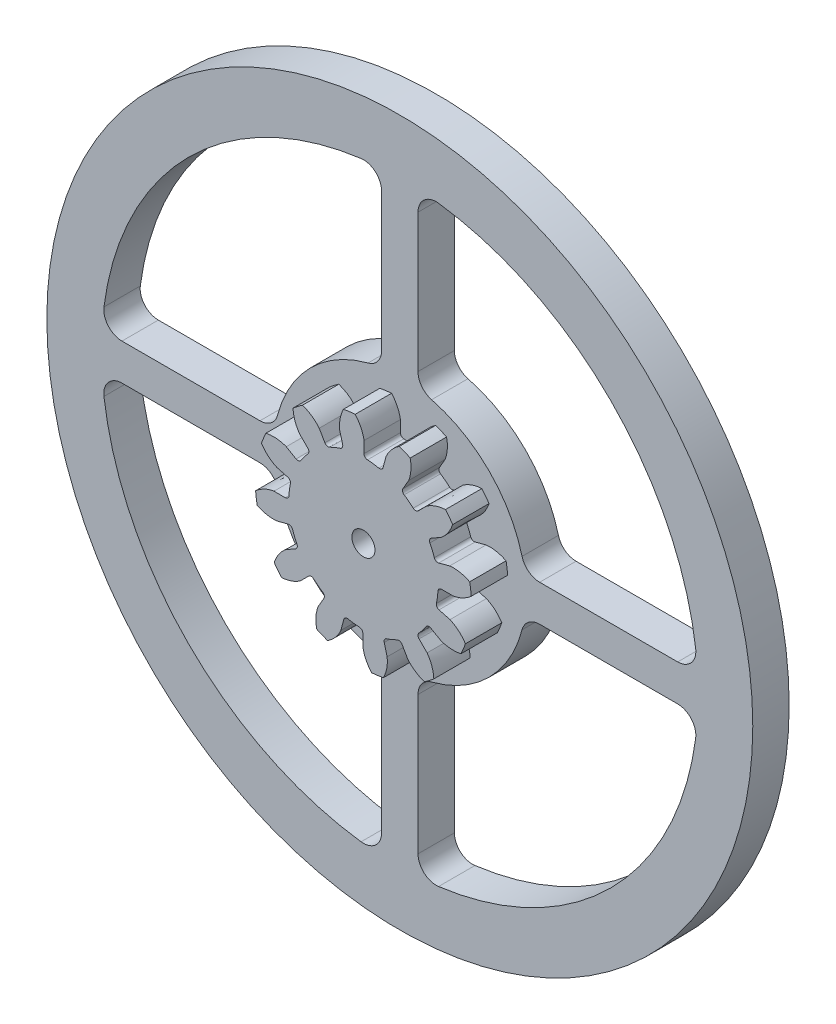
from build123d import *

# Parameters (mm, degrees)
SKETCH1_R                = 14.859
BOSS_EXTRUDE1_DEPTH      = 5
CUT_EXTRUDE1_DEPTH       = 22.600457449
FILLET1_R                = 0.498729
CIRPATTERN1_COUNT        = 12
FILLET1_OF_CIRPATTERN1_R = 0.498729
SKETCH5_R                = 1.5875
CUT_EXTRUDE2_DEPTH       = 22.541370702
SKETCH6_R                = 48.510317
SKETCH6_R_2              = 1.5875
BOSS_EXTRUDE2_DEPTH      = 5
CUT_EXTRUDE3_DEPTH       = 69.785912302


with BuildPart() as part:
    # Sketch1 → Boss-Extrude1 (new body)
    with BuildSketch(Plane.XY):
        Circle(SKETCH1_R)
    extrude(amount=-BOSS_EXTRUDE1_DEPTH)

    # Sketch4 → Cut-Extrude1 (cut, through all)
    with BuildSketch(Plane.XY):
        with BuildLine():
            Line((0.080131787, 12.295213914), (0.080131787, 10.250703468))
            ThreePointArc((0.080131787, 10.250703468), (1.338029283, 10.163317388), (2.575681995, 9.922157274))
            Line((2.575681995, 9.922157274), (3.104841445, 11.897002391))
            add(Edge.make_bspline(
                [(5.071151281, 14.112882844), (3.70540161, 13.261726884), (3.104841445, 11.897002391)],
                knots=[0, 0, 0, 1, 1, 1], degree=2))
            ThreePointArc((5.071151281, 14.112882844), (1.957418943, 14.868037818), (-1.245663981, 14.944509317))
            add(Edge.make_bspline(
                [(-1.245663981, 14.944509317), (-0.146747194, 13.768873094), (0.080131787, 12.295213914)],
                knots=[0, 0, 0, 1, 1, 1], degree=2))
        make_face()
    cut_extrude1 = extrude(amount=-CUT_EXTRUDE1_DEPTH, mode=Mode.SUBTRACT)

    # Fillet1
    fillet1_edges = [part.edges().sort_by_distance(p)[0] for p in [
        (2.575681995, 9.922157274, -2.5),
        (0.080131787, 10.250703468, -2.5),
    ]]
    fillet(fillet1_edges, radius=FILLET1_R)

    # CirPattern1: Cut-Extrude1 ×12 about axis
    cirpattern1_axis = Axis((0, 0, -5), (0, 0, 1))
    for i in range(1, CIRPATTERN1_COUNT):
        add(cut_extrude1.rotate(cirpattern1_axis, i * 360 / CIRPATTERN1_COUNT), mode=Mode.SUBTRACT)

    # Fillet1 of CirPattern1
    fillet1_of_cirpattern1_edges = [part.edges().sort_by_distance(p)[0] for p in [
        (-2.730472597, 9.880681257, -2.5),
        (-5.055955571, 8.917435504, -2.5),
        (-7.304999262, 7.191684677, -2.5),
        (-8.837303717, 5.194747897, -2.5),
        (-9.922157274, 2.575681995, -2.5),
        (-10.250703468, 0.080131787, -2.5),
        (-9.880681257, -2.730472597, -2.5),
        (-8.917435504, -5.055955571, -2.5),
        (-7.191684677, -7.304999262, -2.5),
        (-5.194747897, -8.837303717, -2.5),
        (-2.575681995, -9.922157274, -2.5),
        (-0.080131787, -10.250703468, -2.5),
        (2.730472597, -9.880681257, -2.5),
        (5.055955571, -8.917435504, -2.5),
        (7.304999262, -7.191684677, -2.5),
        (8.837303717, -5.194747897, -2.5),
        (9.922157274, -2.575681995, -2.5),
        (10.250703468, -0.080131787, -2.5),
        (9.880681257, 2.730472597, -2.5),
        (8.917435504, 5.055955571, -2.5),
        (7.191684677, 7.304999262, -2.5),
        (5.194747897, 8.837303717, -2.5),
    ]]
    fillet(fillet1_of_cirpattern1_edges, radius=FILLET1_OF_CIRPATTERN1_R)

    # Sketch5 → Cut-Extrude2 (cut, through all)
    with BuildSketch(Plane.XY):
        Circle(SKETCH5_R)
    extrude(amount=-CUT_EXTRUDE2_DEPTH, mode=Mode.SUBTRACT)

    # Sketch6 → Boss-Extrude2 (add)
    with BuildSketch(Plane(origin=(0, 0, -5), x_dir=(-1, 0, 0), z_dir=(0, 0, -1))):
        Circle(SKETCH6_R)
        with Locations(Location((0, 0, 0), (0, 0, 180))):
            Circle(SKETCH6_R_2, mode=Mode.SUBTRACT)
    extrude(amount=BOSS_EXTRUDE2_DEPTH)

    # Sketch7 → Cut-Extrude3 (cut, through all)
    with BuildSketch(Plane.XY.offset(-5)):
        with BuildLine():
            Line((2.5, 19.219258076), (2.5, 38.18434909))
            ThreePointArc((2.5, 38.18434909), (3.350980725, 40.063374218), (5.324588343, 40.663188013))
            ThreePointArc((5.324588343, 40.663188013), (28.998673249, 28.998673249), (40.663188013, 5.324588343))
            ThreePointArc((40.663188013, 5.324588343), (40.063374218, 3.350980725), (38.18434909, 2.5))
            Line((38.18434909, 2.5), (19.219258076, 2.5))
            ThreePointArc((19.219258076, 2.5), (17.690139676, 3.022173689), (16.799793592, 4.370562465))
            ThreePointArc((16.799793592, 4.370562465), (12.274666615, 12.274666615), (4.370562465, 16.799793592))
            ThreePointArc((4.370562465, 16.799793592), (3.022173689, 17.690139676), (2.5, 19.219258076))
        make_face()
        with BuildLine():
            Line((19.219258076, -2.5), (38.18434909, -2.5))
            ThreePointArc((38.18434909, -2.5), (40.063374218, -3.350980725), (40.663188013, -5.324588343))
            ThreePointArc((40.663188013, -5.324588343), (28.998673249, -28.998673249), (5.324588343, -40.663188013))
            ThreePointArc((5.324588343, -40.663188013), (3.350980725, -40.063374218), (2.5, -38.18434909))
            Line((2.5, -38.18434909), (2.5, -19.219258076))
            ThreePointArc((2.5, -19.219258076), (3.022173689, -17.690139676), (4.370562465, -16.799793592))
            ThreePointArc((4.370562465, -16.799793592), (12.274666615, -12.274666615), (16.799793592, -4.370562465))
            ThreePointArc((16.799793592, -4.370562465), (17.690139676, -3.022173689), (19.219258076, -2.5))
        make_face()
        with BuildLine():
            Line((-2.5, -19.219258076), (-2.5, -38.18434909))
            ThreePointArc((-2.5, -38.18434909), (-3.350980725, -40.063374218), (-5.324588343, -40.663188013))
            ThreePointArc((-5.324588343, -40.663188013), (-28.998673249, -28.998673249), (-40.663188013, -5.324588343))
            ThreePointArc((-40.663188013, -5.324588343), (-40.063374218, -3.350980725), (-38.18434909, -2.5))
            Line((-38.18434909, -2.5), (-19.219258076, -2.5))
            ThreePointArc((-19.219258076, -2.5), (-17.690139676, -3.022173689), (-16.799793592, -4.370562465))
            ThreePointArc((-16.799793592, -4.370562465), (-12.274666615, -12.274666615), (-4.370562465, -16.799793592))
            ThreePointArc((-4.370562465, -16.799793592), (-3.022173689, -17.690139676), (-2.5, -19.219258076))
        make_face()
        with BuildLine():
            Line((-19.219258076, 2.5), (-38.18434909, 2.5))
            ThreePointArc((-38.18434909, 2.5), (-40.063374218, 3.350980725), (-40.663188013, 5.324588343))
            ThreePointArc((-40.663188013, 5.324588343), (-28.998673249, 28.998673249), (-5.324588343, 40.663188013))
            ThreePointArc((-5.324588343, 40.663188013), (-3.350980725, 40.063374218), (-2.5, 38.18434909))
            Line((-2.5, 38.18434909), (-2.5, 19.219258076))
            ThreePointArc((-2.5, 19.219258076), (-3.022173689, 17.690139676), (-4.370562465, 16.799793592))
            ThreePointArc((-4.370562465, 16.799793592), (-12.274666615, 12.274666615), (-16.799793592, 4.370562465))
            ThreePointArc((-16.799793592, 4.370562465), (-17.690139676, 3.022173689), (-19.219258076, 2.5))
        make_face()
    extrude(amount=-CUT_EXTRUDE3_DEPTH, mode=Mode.SUBTRACT)


solid = part.part
